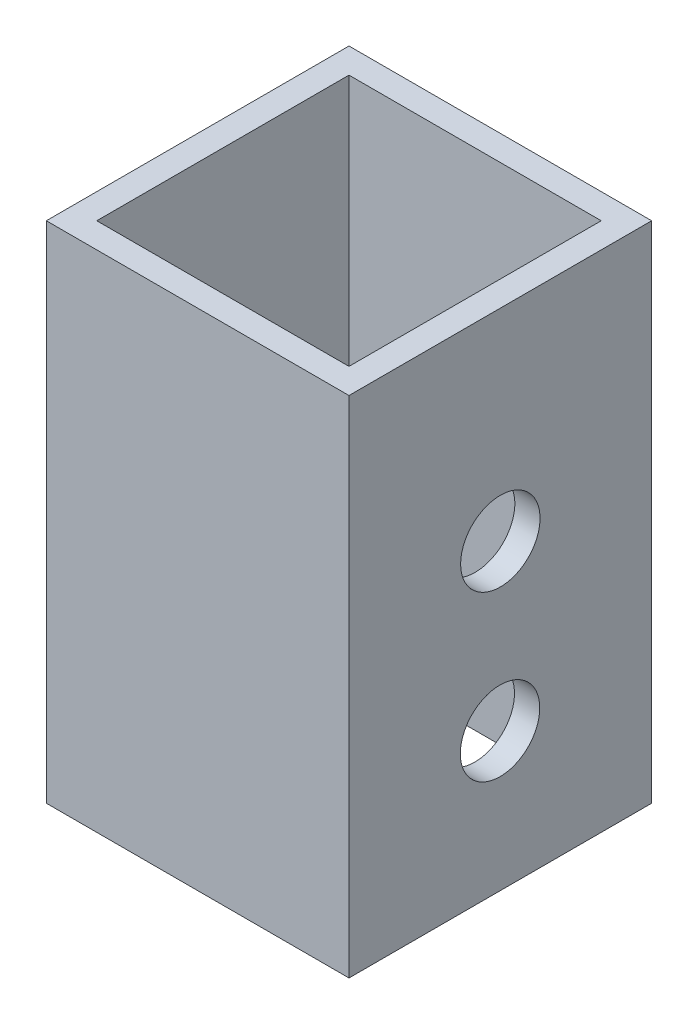
from build123d import *

# Parameters (mm, degrees)
SKETCH1_W           = 76.2
SKETCH1_H           = 76.2
SKETCH1_W_2         = 63.5
SKETCH1_H_2         = 63.5
BOSS_EXTRUDE3_DEPTH = 127
CUT_EXTRUDE4_REACH  = 154.928
SKETCH5_R           = 2.4765
SKETCH5_3_R         = 10
CUT_EXTRUDE5_DEPTH  = 153.928251151
SKETCH6_R           = 10
CUT_EXTRUDE6_DEPTH  = 153.928251151


with BuildPart() as part:
    # Sketch1 → Boss-Extrude3 (new body)
    with BuildSketch(Plane(origin=(0, 0, 0), x_dir=(1, 0, 0), z_dir=(0, 1, 0))):
        Rectangle(SKETCH1_W, SKETCH1_H)
        Rectangle(SKETCH1_W_2, SKETCH1_H_2, mode=Mode.SUBTRACT)
    extrude(amount=BOSS_EXTRUDE3_DEPTH)

    # Sketch5 → Cut-Extrude4 (cut, up to next)
    with BuildSketch(Plane.ZY.offset(38.1), mode=Mode.PRIVATE) as cut_extrude4_sk1:
        with Locations((-23.493043794, 58.456697864)):
            Circle(SKETCH5_R)
    cut_extrude4_tool1 = extrude(cut_extrude4_sk1.sketch, amount=-CUT_EXTRUDE4_REACH, mode=Mode.PRIVATE) & part.part
    # Sketch5 → Cut-Extrude4 (cut, up to next)
    with BuildSketch(Plane.ZY.offset(38.1), mode=Mode.PRIVATE) as cut_extrude4_sk2:
        with Locations((23.653300841, 58.456697864)):
            Circle(SKETCH5_R)
    cut_extrude4_tool2 = extrude(cut_extrude4_sk2.sketch, amount=-CUT_EXTRUDE4_REACH, mode=Mode.PRIVATE) & part.part
    # Sketch5 → Cut-Extrude4 (cut, up to next)
    with BuildSketch(Plane.ZY.offset(38.1), mode=Mode.PRIVATE) as cut_extrude4_sk3:
        with Locations((23.653300841, 11.310353228)):
            Circle(SKETCH5_R)
    cut_extrude4_tool3 = extrude(cut_extrude4_sk3.sketch, amount=-CUT_EXTRUDE4_REACH, mode=Mode.PRIVATE) & part.part
    # Sketch5 → Cut-Extrude4 (cut, up to next)
    with BuildSketch(Plane.ZY.offset(38.1), mode=Mode.PRIVATE) as cut_extrude4_sk4:
        with Locations((-23.493043794, 11.310353228)):
            Circle(SKETCH5_R)
    cut_extrude4_tool4 = extrude(cut_extrude4_sk4.sketch, amount=-CUT_EXTRUDE4_REACH, mode=Mode.PRIVATE) & part.part
    add(cut_extrude4_tool1.solids().sort_by_distance((-38.1, 58.456698, -23.493044))[0], mode=Mode.SUBTRACT)
    add(cut_extrude4_tool2.solids().sort_by_distance((-38.1, 58.456698, 23.653301))[0], mode=Mode.SUBTRACT)
    add(cut_extrude4_tool3.solids().sort_by_distance((-38.1, 11.310353, 23.653301))[0], mode=Mode.SUBTRACT)
    add(cut_extrude4_tool4.solids().sort_by_distance((-38.1, 11.310353, -23.493044))[0], mode=Mode.SUBTRACT)

    # Sketch5_3 → Cut-Extrude5 (cut, through all)
    with BuildSketch(Plane.ZY.offset(38.1)):
        with Locations((0.080128523, 34.883525546)):
            Circle(SKETCH5_3_R)
    extrude(amount=-CUT_EXTRUDE5_DEPTH, mode=Mode.SUBTRACT)

    # Sketch6 → Cut-Extrude6 (cut, through all)
    with BuildSketch(Plane.ZY.offset(38.1)):
        with Locations((0, 76.2)):
            Circle(SKETCH6_R)
    extrude(amount=-CUT_EXTRUDE6_DEPTH, mode=Mode.SUBTRACT)


solid = part.part
